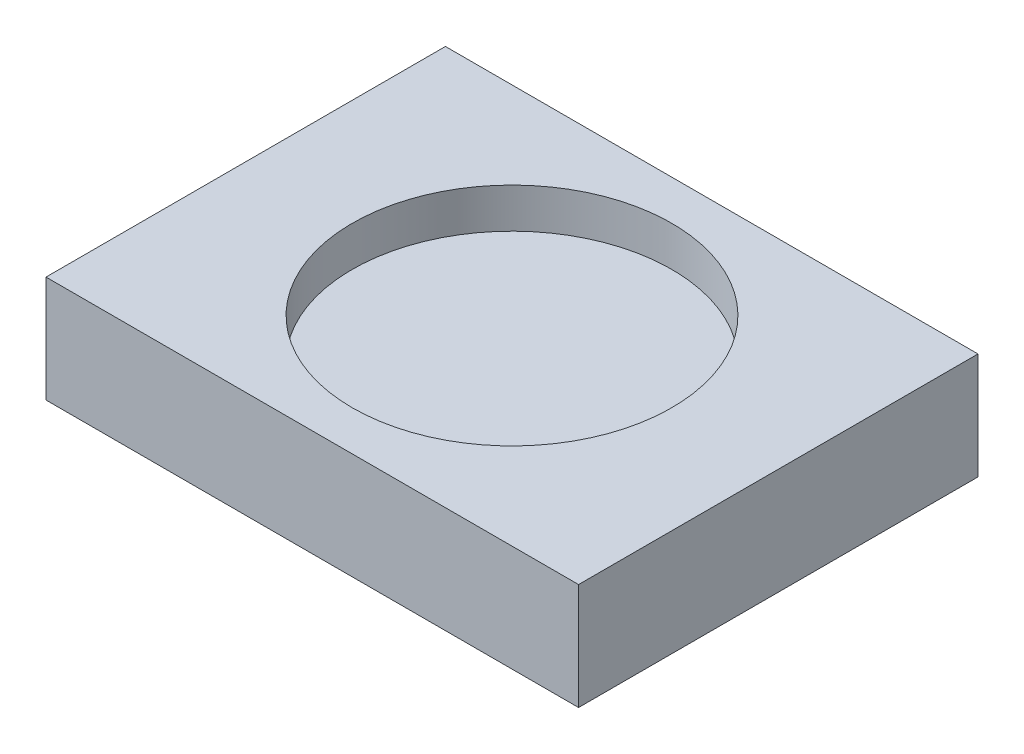
from build123d import *

# Parameters (mm, degrees)
SKETCH1_W           = 200
SKETCH1_H           = 150
BOSS_EXTRUDE1_DEPTH = 40
SKETCH2_R           = 60
CUT_EXTRUDE1_DEPTH  = 15


with BuildPart() as part:
    # Sketch1 → Boss-Extrude1 (new body)
    with BuildSketch(Plane(origin=(0, 0, 0), x_dir=(1, 0, 0), z_dir=(0, 1, 0))):
        Rectangle(SKETCH1_W, SKETCH1_H)
    extrude(amount=BOSS_EXTRUDE1_DEPTH)

    # Sketch2 → Cut-Extrude1 (cut)
    with BuildSketch(Plane(origin=(0, 40, 0), x_dir=(1, 0, 0), z_dir=(0, 1, 0))):
        Circle(SKETCH2_R)
    extrude(amount=-CUT_EXTRUDE1_DEPTH, mode=Mode.SUBTRACT)


solid = part.part
